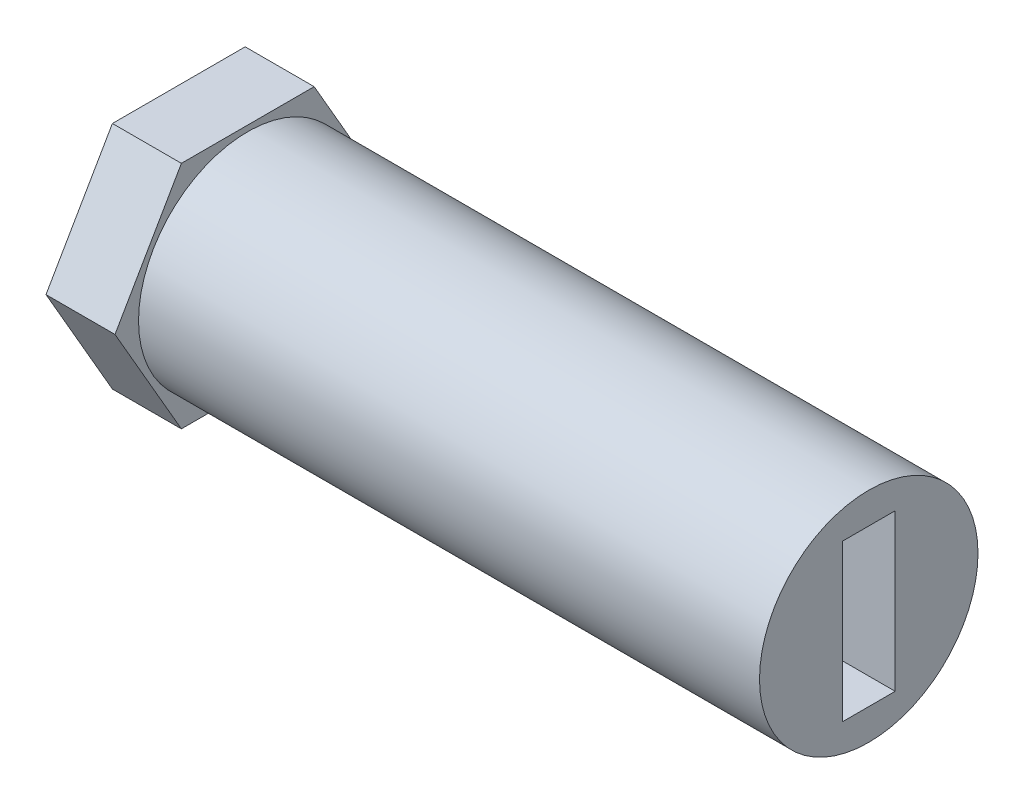
from build123d import *

# Parameters (mm, degrees)
SKETCH1_R           = 4.75
BOSS_EXTRUDE1_DEPTH = 30
SKETCH2_W           = 2.3
SKETCH2_H           = 6.8
CUT_EXTRUDE1_DEPTH  = 30
BOSS_EXTRUDE2_DEPTH = 3


with BuildPart() as part:
    # Sketch1 → Boss-Extrude1 (new body)
    with BuildSketch(Plane(origin=(0, 0, 0), x_dir=(0, 0, -1), z_dir=(1, 0, 0))):
        Circle(SKETCH1_R)
    extrude(amount=BOSS_EXTRUDE1_DEPTH)

    # Sketch2 → Cut-Extrude1 (cut)
    with BuildSketch(Plane(origin=(30, 0, 0), x_dir=(0, 0, -1), z_dir=(1, 0, 0))):
        Rectangle(SKETCH2_W, SKETCH2_H)
    extrude(amount=-CUT_EXTRUDE1_DEPTH, mode=Mode.SUBTRACT)

    # Sketch3 → Boss-Extrude2 (add)
    with BuildSketch(Plane.ZY):
        Polygon((5.773502692, 0), (2.886751346, 5), (-2.886751346, 5), (-5.773502692, 0), (-2.886751346, -5), (2.886751346, -5), align=None)
    extrude(amount=-BOSS_EXTRUDE2_DEPTH)


solid = part.part
